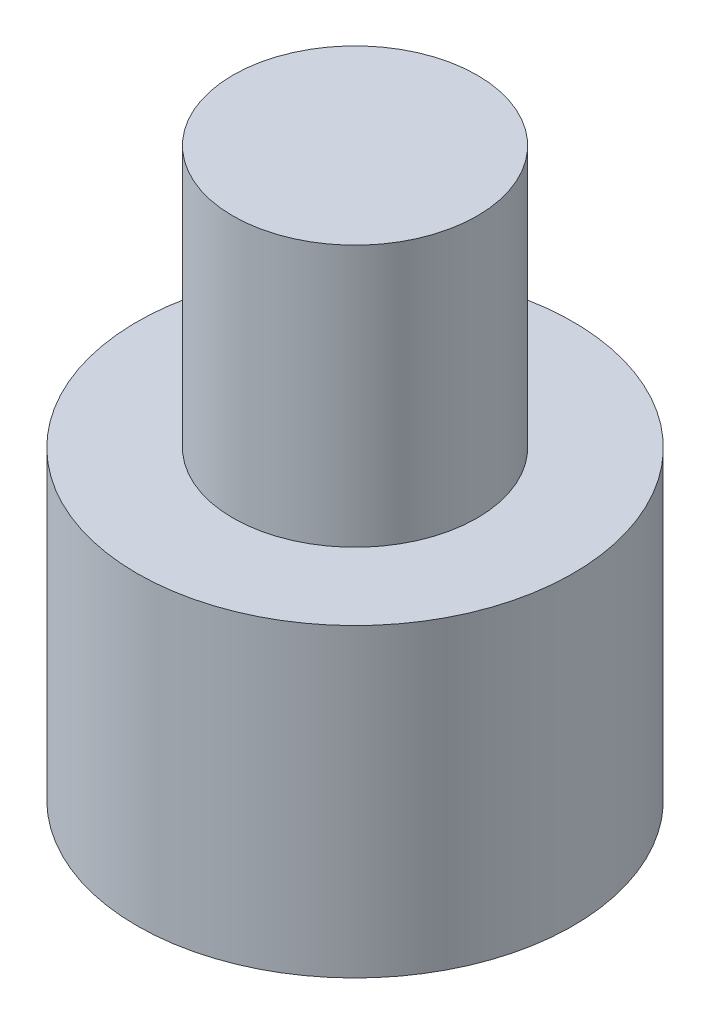
from build123d import *

# Parameters (mm, degrees)
ESQUISSE1_R        = 1.4
BOSS_EXTRU_1_DEPTH = 6.5
ESQUISSE2_R        = 2.5
BOSS_EXTRU_2_DEPTH = 3.5


with BuildPart() as part:
    # Esquisse1 → Boss.-Extru.1 (new body)
    with BuildSketch(Plane(origin=(0, 0, 0), x_dir=(1, 0, 0), z_dir=(0, 1, 0))):
        Circle(ESQUISSE1_R)
    extrude(amount=BOSS_EXTRU_1_DEPTH)

    # Esquisse2 → Boss.-Extru.2 (add)
    with BuildSketch(Plane(origin=(0, 0, 0), x_dir=(1, 0, 0), z_dir=(0, 1, 0))):
        Circle(ESQUISSE2_R)
    extrude(amount=BOSS_EXTRU_2_DEPTH)


solid = part.part
